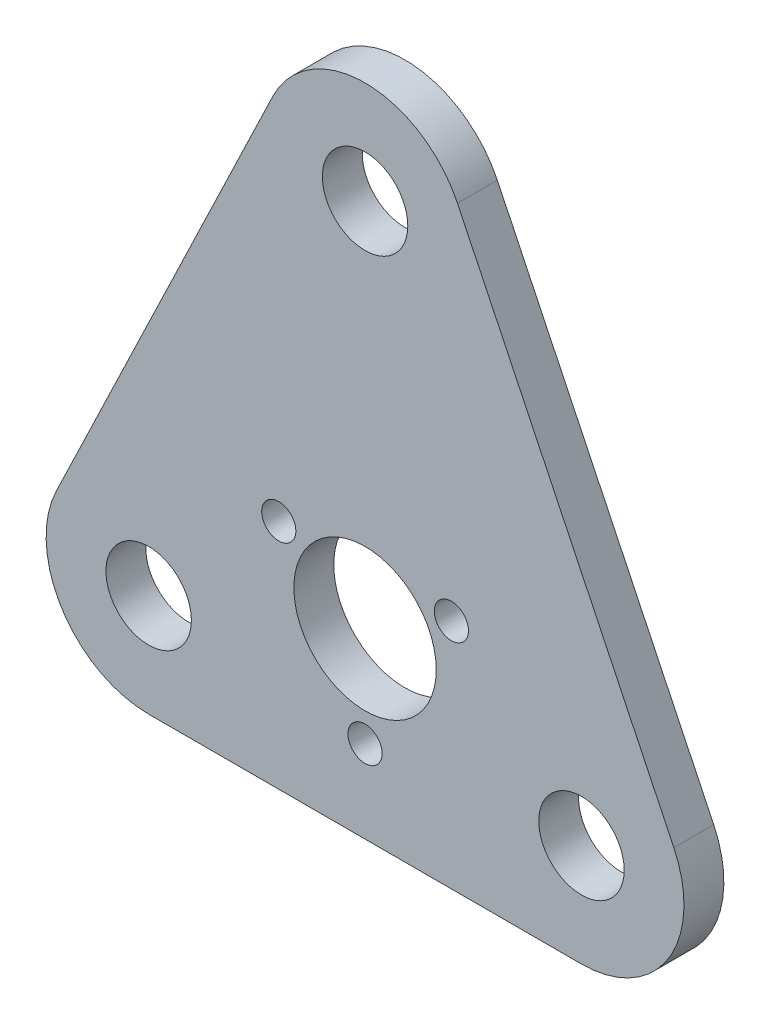
from build123d import *

# Parameters (mm, degrees)
SKETCH1_R           = 7.5
SKETCH1_R_2         = 12.5
SKETCH1_R_3         = 3
BOSS_EXTRUDE1_DEPTH = 3.5


with BuildPart() as part:
    # Sketch1 → Boss-Extrude1 (new body, symmetric)
    with BuildSketch(Plane.XY):
        with BuildLine():
            Line((-38, -18), (38, -18))
            ThreePointArc((38, -18), (53.238850443, -9.580054133), (54.221001351, 7.802506979))
            Line((54.221001351, 7.802506979), (16.221001351, 86.802506979))
            ThreePointArc((16.221001351, 86.802506979), (0, 97), (-16.221001351, 86.802506979))
            Line((-16.221001351, 86.802506979), (-54.221001351, 7.802506979))
            ThreePointArc((-54.221001351, 7.802506979), (-53.238850443, -9.580054133), (-38, -18))
        make_face()
        with Locations((-38, 0)):
            Circle(SKETCH1_R, mode=Mode.SUBTRACT)
        with Locations((38, 0)):
            Circle(SKETCH1_R, mode=Mode.SUBTRACT)
        with Locations((0, 14)):
            Circle(SKETCH1_R_2, mode=Mode.SUBTRACT)
        with Locations((-15.155444566, 22.75)):
            Circle(SKETCH1_R_3, mode=Mode.SUBTRACT)
        with Locations((0, -3.5)):
            Circle(SKETCH1_R_3, mode=Mode.SUBTRACT)
        with Locations((15.155444566, 22.75)):
            Circle(SKETCH1_R_3, mode=Mode.SUBTRACT)
        with Locations((0, 79)):
            Circle(SKETCH1_R, mode=Mode.SUBTRACT)
    extrude(amount=BOSS_EXTRUDE1_DEPTH, both=True)


solid = part.part
